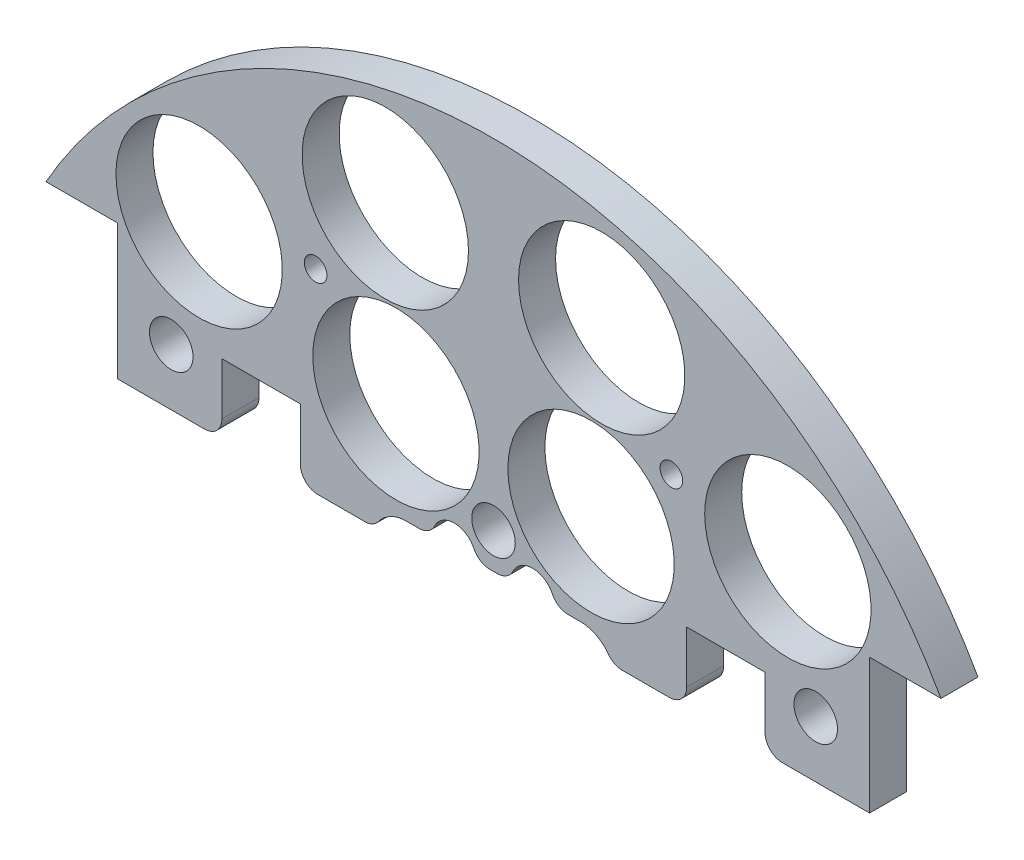
from build123d import *

# Parameters (mm, degrees)
SKETCH1_R                 = 1.651
BOSS_EXTRUDE2_DEPTH       = 5.3975
SKETCH2_R                 = 1.143
CUT_EXTRUDE1_DEPTH        = 6.3975
SKETCH3_R                 = 12.1285
CUT_EXTRUDE2_DEPTH        = 6.3975
SKETCH4_W                 = 28.562713242
SKETCH4_H                 = 11.677503754
BOSS_EXTRUDE3_DEPTH       = 5.3975
SKETCH5_W                 = 230.699333954
SKETCH5_H                 = 107.587024537
CUT_EXTRUDE3_DEPTH        = 6.3975
SKETCH6_R                 = 12.1285
CUT_EXTRUDE4_DEPTH        = 6.3975
SKETCH162_W               = 11.43
SKETCH162_H               = 10.16
CUT_EXTRUDE159_DEPTH      = 6.3975
SKETCH202_R               = 1.651
CUT_EXTRUDE199_DEPTH      = 35.56
SKETCH203_R               = 3.175
CUT_EXTRUDE200_DEPTH      = 103.378
CUT_EXTRUDE200_DEPTH_BACK = 48.768
CUT_EXTRUDE162_DEPTH      = 30.48
FILLET1_R                 = 2.54


with BuildPart() as part:
    # Sketch1 → Boss-Extrude2 (new body)
    with BuildSketch(Plane.XY):
        with BuildLine():
            Line((-65.2537815, 36.83), (-54.8397815, 36.83))
            Line((-54.8397815, 36.83), (-54.8397815, -36.83))
            Line((-54.8397815, -36.83), (-65.2537815, -36.83))
            ThreePointArc((-65.2537815, -36.83), (0, -74.93), (65.2537815, -36.83))
            Line((65.2537815, -36.83), (54.8397815, -36.83))
            Line((54.8397815, -36.83), (54.8397815, 36.83))
            Line((54.8397815, 36.83), (65.2537815, 36.83))
            ThreePointArc((65.2537815, 36.83), (0, 74.93), (-65.2537815, 36.83))
        make_face()
        with Locations((-45.466, 11.049)):
            Circle(SKETCH1_R, mode=Mode.SUBTRACT)
        with Locations((-20.067270032, 10.795)):
            Circle(SKETCH1_R, mode=Mode.SUBTRACT)
        with Locations((-20.067270032, -10.795)):
            Circle(SKETCH1_R, mode=Mode.SUBTRACT)
        with Locations((-45.466, -11.049)):
            Circle(SKETCH1_R, mode=Mode.SUBTRACT)
        with Locations((45.466, -11.049)):
            Circle(SKETCH1_R, mode=Mode.SUBTRACT)
        with Locations((20.067270032, -10.795)):
            Circle(SKETCH1_R, mode=Mode.SUBTRACT)
        with Locations((20.067270032, 10.795)):
            Circle(SKETCH1_R, mode=Mode.SUBTRACT)
        with Locations((45.466, 11.049)):
            Circle(SKETCH1_R, mode=Mode.SUBTRACT)
    extrude(amount=BOSS_EXTRUDE2_DEPTH)

    # Sketch2 → Cut-Extrude1 (cut, through all)
    with BuildSketch(Plane.XY.offset(5.3975)):
        with Locations((-6.731, 62.23)):
            Circle(SKETCH2_R)
        with Locations((6.731, 62.23)):
            Circle(SKETCH2_R)
    extrude(amount=-CUT_EXTRUDE1_DEPTH, mode=Mode.SUBTRACT)

    # Sketch3 → Cut-Extrude2 (cut, through all)
    with BuildSketch(Plane(origin=(0, 0, 0), x_dir=(-1, 0, 0), z_dir=(0, 0, -1))):
        with Locations((-14.224, -56.725087043)):
            Circle(SKETCH3_R)
        with Locations((14.224, -56.725087043)):
            Circle(SKETCH3_R)
        with Locations((-42.926, -42.926)):
            Circle(SKETCH3_R)
        with Locations((14.224, 34.29)):
            Circle(SKETCH3_R)
        with Locations((-14.224, 34.29)):
            Circle(SKETCH3_R)
        with Locations((-42.926, 42.926)):
            Circle(SKETCH3_R)
        with Locations((42.926, 42.926)):
            Circle(SKETCH3_R)
        with Locations((42.926, -42.926)):
            Circle(SKETCH3_R)
    extrude(amount=-CUT_EXTRUDE2_DEPTH, mode=Mode.SUBTRACT)

    # Sketch4 → Boss-Extrude3 (add)
    with BuildSketch(Plane(origin=(0, 0, 0), x_dir=(-1, 0, 0), z_dir=(0, 0, -1))):
        with Locations((-1.488809975, 62.152540216)):
            Rectangle(SKETCH4_W, SKETCH4_H)
    extrude(amount=-BOSS_EXTRUDE3_DEPTH)

    # Sketch5 → Cut-Extrude3 (cut, through all)
    with BuildSketch(Plane(origin=(0, 0, 0), x_dir=(-1, 0, 0), z_dir=(0, 0, -1))):
        with Locations((1.971047261, -36.648512269)):
            Rectangle(SKETCH5_W, SKETCH5_H)
    extrude(amount=-CUT_EXTRUDE3_DEPTH, mode=Mode.SUBTRACT)

    # Sketch6 → Cut-Extrude4 (cut, through all)
    with BuildSketch(Plane(origin=(0, 0, 0), x_dir=(-1, 0, 0), z_dir=(0, 0, -1))):
        with Locations((-15.777608989, 58.882838371)):
            Circle(SKETCH6_R)
        with Locations((15.777608989, 58.882838371)):
            Circle(SKETCH6_R)
    extrude(amount=-CUT_EXTRUDE4_DEPTH, mode=Mode.SUBTRACT)

    # Sketch162 → Cut-Extrude159 (cut, through all)
    with BuildSketch(Plane.XY.offset(5.3975)):
        with Locations((33.8847815, 22.225)):
            Rectangle(SKETCH162_W, SKETCH162_H)
        with Locations((-33.8847815, 22.225)):
            Rectangle(SKETCH162_W, SKETCH162_H)
    extrude(amount=-CUT_EXTRUDE159_DEPTH, mode=Mode.SUBTRACT)

    # Sketch202 → Cut-Extrude199 (cut)
    with BuildSketch(Plane(origin=(0, 0, 0), x_dir=(-1, 0, 0), z_dir=(0, 0, -1))):
        with Locations((25.937608989, 45.466)):
            Circle(SKETCH202_R)
        with Locations((-25.937608989, 45.466)):
            Circle(SKETCH202_R)
    extrude(amount=-CUT_EXTRUDE199_DEPTH, mode=Mode.SUBTRACT)

    # Sketch203 → Cut-Extrude200 (cut, two sides)
    with BuildSketch(Plane(origin=(30.092005081, 4.08352975, 30.734), x_dir=(-1, 0, 0), z_dir=(0, 0, -1))) as cut_extrude200_sk:
        with Locations((-16.897994919, 21.31647025)):
            Circle(SKETCH203_R)
        with Locations((77.082005081, 21.31647025)):
            Circle(SKETCH203_R)
        with Locations((30.092005081, 21.31647025)):
            Circle(SKETCH203_R)
    extrude(amount=CUT_EXTRUDE200_DEPTH, mode=Mode.SUBTRACT)
    extrude(cut_extrude200_sk.sketch, amount=-CUT_EXTRUDE200_DEPTH_BACK, mode=Mode.SUBTRACT)

    # Sketch165 → Cut-Extrude162 (cut)
    with BuildSketch(Plane(origin=(0, 0, 0), x_dir=(-1, 0, 0), z_dir=(0, 0, -1))):
        with BuildLine():
            Line((12.7, 20.24), (8.888991966, 20.24))
            ThreePointArc((8.888991966, 20.24), (5.715, 23.495), (2.541008034, 20.24))
            Line((2.541008034, 20.24), (-2.541008034, 20.24))
            ThreePointArc((-2.541008034, 20.24), (-5.715, 23.495), (-8.888991966, 20.24))
            Line((-8.888991966, 20.24), (-12.7, 20.24))
            ThreePointArc((-12.7, 20.24), (-16.235533906, 11.704466094), (-7.7, 15.24))
            Line((-7.7, 15.24), (7.7, 15.24))
            ThreePointArc((7.7, 15.24), (16.235533906, 11.704466094), (12.7, 20.24))
        make_face()
    extrude(amount=-CUT_EXTRUDE162_DEPTH, mode=Mode.SUBTRACT)

    # Fillet1
    fillet1_edges = [part.edges().sort_by_distance(p)[0] for p in [
        (39.5997815, 17.145, 2.69875),
        (28.1697815, 17.145, 2.69875),
        (-28.1697815, 17.145, 2.69875),
        (-39.5997815, 17.145, 2.69875),
        (-17.322875188, 17.145, 2.69875),
        (17.322875188, 17.145, 2.69875),
        (8.888991966, 20.24, 2.69875),
        (2.541008034, 20.24, 2.69875),
        (-2.541008034, 20.24, 2.69875),
        (-8.888991966, 20.24, 2.69875),
    ]]
    fillet(fillet1_edges, radius=FILLET1_R)


solid = part.part
